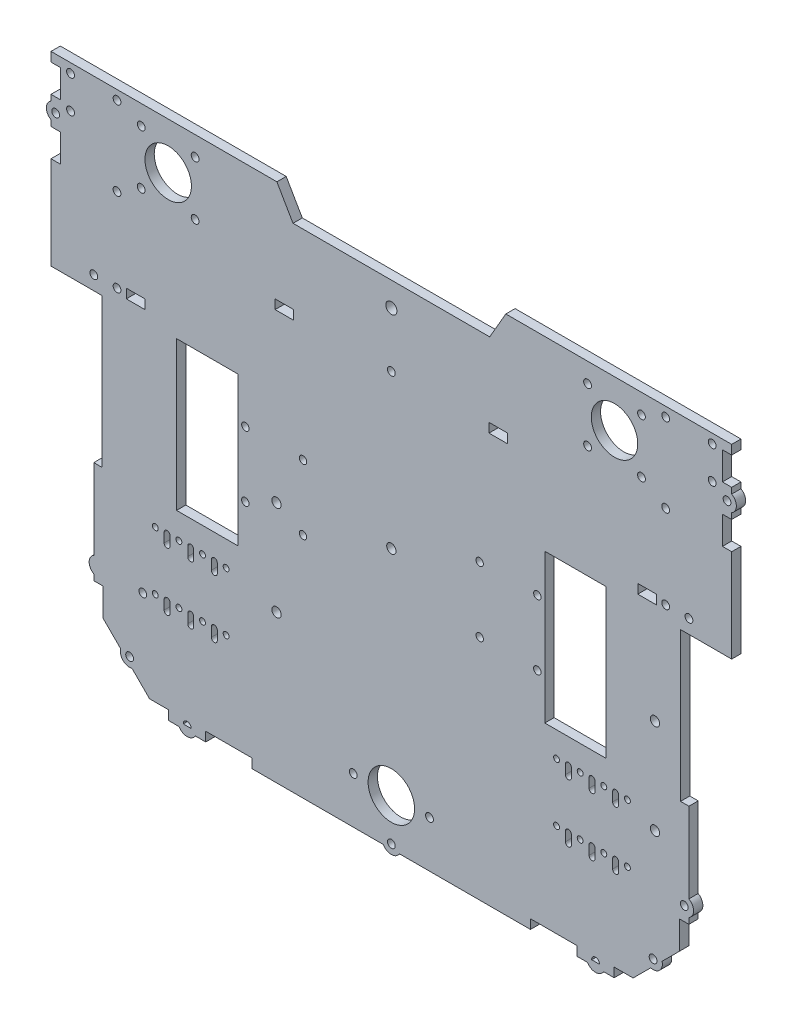
from build123d import *

# Parameters (mm, degrees)
SKETCH1_W            = 320
SKETCH1_H            = 280
BOSS_EXTRUDE1_DEPTH  = 5
SKETCH2_W            = 77.5
SKETCH2_H            = 80
CUT_EXTRUDE1_DEPTH   = 5
SKETCH3_W            = 17.5
SKETCH3_H            = 80
BOSS_EXTRUDE2_DEPTH  = 5
CUT_EXTRUDE8_DEPTH   = 5
SKETCH10_W           = 5
SKETCH10_H           = 100
BOSS_EXTRUDE3_DEPTH  = 20
SKETCH5_R            = 2.1
CUT_EXTRUDE9_DEPTH   = 10
SKETCH12_W           = 5
SKETCH12_H           = 35.2
SKETCH12_W_2         = 60.2
SKETCH12_H_2         = 5
CUT_EXTRUDE11_DEPTH  = 10
SKETCH15_R           = 2
SKETCH15_R_2         = 2.5
CUT_EXTRUDE13_DEPTH  = 10
SKETCH16_R           = 2.5
CUT_EXTRUDE14_DEPTH  = 10
SKETCH17_R           = 12.5
SKETCH17_R_2         = 2.1
CUT_EXTRUDE15_DEPTH  = 5
CUT_EXTRUDE17_DEPTH  = 10
SKETCH19_R           = 12.5
SKETCH19_R_2         = 2.1
CUT_EXTRUDE18_DEPTH  = 10
SKETCH21_W           = 5
SKETCH21_H           = 100
CUT_EXTRUDE20_DEPTH  = 3
SKETCH22_W           = 5
SKETCH22_H           = 100
CUT_EXTRUDE21_DEPTH  = 3
SKETCH23_R           = 2.1
CUT_EXTRUDE22_DEPTH  = 10
BOSS_EXTRUDE4_DEPTH  = 5
SKETCH26_W           = 20
SKETCH26_H           = 5
BOSS_EXTRUDE5_DEPTH  = 5
SKETCH27_R           = 2.1
CUT_EXTRUDE24_DEPTH  = 5
BOSS_EXTRUDE7_DEPTH  = 5
SKETCH30_W           = 5
SKETCH30_H           = 80
BOSS_EXTRUDE8_DEPTH  = 5
SKETCH31_W           = 5
SKETCH31_H           = 80
BOSS_EXTRUDE9_DEPTH  = 5
SKETCH32_R           = 2.1
CUT_EXTRUDE25_DEPTH  = 5
BOSS_EXTRUDE10_DEPTH = 5
SKETCH34_R           = 3
CUT_EXTRUDE26_DEPTH  = 5
SKETCH35_R           = 2.1
SKETCH35_W           = 10
SKETCH35_H           = 5
CUT_EXTRUDE27_DEPTH  = 5
SKETCH37_W           = 5
SKETCH37_H           = 5
BOSS_EXTRUDE11_DEPTH = 0.2
SKETCH38_W           = 5
SKETCH38_H           = 5
BOSS_EXTRUDE12_DEPTH = 0.2
SKETCH39_R           = 2.1
CUT_EXTRUDE28_DEPTH  = 5
BOSS_EXTRUDE13_DEPTH = 5
SKETCH42_R           = 1.5875
CUT_EXTRUDE29_DEPTH  = 10
SKETCH43_W           = 5
SKETCH43_H           = 100
BOSS_EXTRUDE14_DEPTH = 6
SKETCH44_W           = 5
SKETCH44_H           = 100
BOSS_EXTRUDE15_DEPTH = 6
SKETCH54_W           = 10
SKETCH54_H           = 5
CUT_EXTRUDE34_DEPTH  = 5
SKETCH56_W           = 4.979498839
SKETCH56_H           = 15
CUT_EXTRUDE36_DEPTH  = 5
SKETCH57_R           = 2.1
CUT_EXTRUDE37_DEPTH  = 10
SKETCH58_R           = 2.1
CUT_EXTRUDE38_DEPTH  = 5
BOSS_EXTRUDE21_DEPTH = 5
SKETCH60_W           = 5
SKETCH60_H           = 80
BOSS_EXTRUDE22_DEPTH = 17.5
SKETCH61_W           = 5
SKETCH61_H           = 80
BOSS_EXTRUDE23_DEPTH = 17.5
BOSS_EXTRUDE24_DEPTH = 5


with BuildPart() as part:
    # Sketch1 → Boss-Extrude1 (new body)
    with BuildSketch(Plane.XY):
        with Locations((-160, 140)):
            Rectangle(SKETCH1_W, SKETCH1_H)
    extrude(amount=BOSS_EXTRUDE1_DEPTH)

    # Sketch2 → Cut-Extrude1 (cut)
    with BuildSketch(Plane.XY.offset(5)):
        with Locations((-281.25, 140)):
            Rectangle(SKETCH2_W, SKETCH2_H)
        with Locations((-38.75, 140)):
            Rectangle(SKETCH2_W, SKETCH2_H)
    extrude(amount=-CUT_EXTRUDE1_DEPTH, mode=Mode.SUBTRACT)

    # Sketch3 → Boss-Extrude2 (add)
    with BuildSketch(Plane.XY.offset(5)):
        with Locations((-301.75, 140)):
            Rectangle(SKETCH3_W, SKETCH3_H)
        with Locations((-18.25, 140)):
            Rectangle(SKETCH3_W, SKETCH3_H)
    extrude(amount=-BOSS_EXTRUDE2_DEPTH)

    # Sketch9 → Cut-Extrude8 (cut)
    with BuildSketch(Plane(origin=(0, 0, 0), x_dir=(-1, 0, 0), z_dir=(0, 0, -1))):
        Polygon((210, 260), (260, 346.602540378), (210, 433.205080757), (110, 433.205080757), (60, 346.602540378), (110, 260), align=None)
    extrude(amount=-CUT_EXTRUDE8_DEPTH, mode=Mode.SUBTRACT)

    # Sketch10 → Boss-Extrude3 (add)
    with BuildSketch(Plane.ZY.offset(320)):
        with Locations((2.5, 230)):
            Rectangle(SKETCH10_W, SKETCH10_H)
    boss_extrude3 = extrude(amount=BOSS_EXTRUDE3_DEPTH)

    # Mirror2: Boss-Extrude3 across plane
    add(boss_extrude3.mirror(Plane(origin=(-160, 0, 0), x_dir=(0, 0, 1), z_dir=(1, 0, 0))))

    # Sketch5 → Cut-Extrude9 (cut)
    with BuildSketch(Plane.XY.offset(5)):
        with Locations((12.5, 257.5)):
            Circle(SKETCH5_R)
        with Locations((-12.5, 232.5)):
            Circle(SKETCH5_R)
        with Locations((-12.5, 187.5)):
            Circle(SKETCH5_R)
        with Locations((12.5, 162.5)):
            Circle(SKETCH5_R)
        with Locations((-12.5, 275)):
            Circle(SKETCH5_R)
        with Locations((12.5, 275)):
            Circle(SKETCH5_R)
    cut_extrude9 = extrude(amount=-CUT_EXTRUDE9_DEPTH, mode=Mode.SUBTRACT)

    # Mirror3: Cut-Extrude9 across plane
    add(cut_extrude9.mirror(Plane(origin=(-160, 0, 0), x_dir=(0, 0, 1), z_dir=(1, 0, 0))), mode=Mode.SUBTRACT)

    # Sketch12 → Cut-Extrude11 (cut)
    with BuildSketch(Plane.XY.offset(5)):
        with Locations((-2.5, 27.6)):
            Rectangle(SKETCH12_W, SKETCH12_H)
        with Locations((-317.5, 27.6)):
            Rectangle(SKETCH12_W, SKETCH12_H)
        with Locations((-264.9, 2.5)):
            Rectangle(SKETCH12_W_2, SKETCH12_H_2)
        with Locations((-55.1, 2.5)):
            Rectangle(SKETCH12_W_2, SKETCH12_H_2)
    extrude(amount=-CUT_EXTRUDE11_DEPTH, mode=Mode.SUBTRACT)

    # Sketch15 → Cut-Extrude13 (cut)
    with BuildSketch(Plane(origin=(0, 0, 0), x_dir=(-1, 0, 0), z_dir=(0, 0, -1))):
        with Locations((238.5, 122.5)):
            Circle(SKETCH15_R)
        with Locations((238.5, 157.5)):
            Circle(SKETCH15_R)
        with Locations((207.5, 157.5)):
            Circle(SKETCH15_R)
        with Locations((207.5, 122.5)):
            Circle(SKETCH15_R)
        with Locations((112.5, 122.5)):
            Circle(SKETCH15_R)
        with Locations((112.5, 157.5)):
            Circle(SKETCH15_R)
        with Locations((81.5, 157.5)):
            Circle(SKETCH15_R)
        with Locations((81.5, 122.5)):
            Circle(SKETCH15_R)
        with Locations((160, 140)):
            Circle(SKETCH15_R_2)
    extrude(amount=-CUT_EXTRUDE13_DEPTH, mode=Mode.SUBTRACT)

    # Sketch16 → Cut-Extrude14 (cut)
    with BuildSketch(Plane(origin=(0, 0, 0), x_dir=(-1, 0, 0), z_dir=(0, 0, -1))):
        with Locations((18.25, 130.5)):
            Circle(SKETCH16_R)
        with Locations((18.25, 79.5)):
            Circle(SKETCH16_R)
        with Locations((221.75, 79.5)):
            Circle(SKETCH16_R)
        with Locations((221.75, 130.5)):
            Circle(SKETCH16_R)
    extrude(amount=-CUT_EXTRUDE14_DEPTH, mode=Mode.SUBTRACT)

    # Sketch17 → Cut-Extrude15 (cut)
    with BuildSketch(Plane(origin=(0, 0, 0), x_dir=(-1, 0, 0), z_dir=(0, 0, -1))):
        with Locations((40, 255)):
            Circle(SKETCH17_R)
        with Locations((54.495689014, 240.504310986)):
            Circle(SKETCH17_R_2)
        with Locations((25.504310986, 269.495689014)):
            Circle(SKETCH17_R_2)
        with Locations((54.495689014, 269.495689014)):
            Circle(SKETCH17_R_2)
        with Locations((25.504310986, 240.504310986)):
            Circle(SKETCH17_R_2)
        with Locations((265.504310986, 269.495689014)):
            Circle(SKETCH17_R_2)
        with Locations((294.495689014, 240.504310986)):
            Circle(SKETCH17_R_2)
        with Locations((294.495689014, 269.495689014)):
            Circle(SKETCH17_R_2)
        with Locations((265.504310986, 240.504310986)):
            Circle(SKETCH17_R_2)
        with Locations((280, 255)):
            Circle(SKETCH17_R)
    extrude(amount=-CUT_EXTRUDE15_DEPTH, mode=Mode.SUBTRACT)

    # Sketch18 → Cut-Extrude17 (cut)
    with BuildSketch(Plane.XY.offset(5)):
        Polygon((-290, 5), (-315, 30), (-315, 10), (-320, 10), (-320, 0), (-295, 0), (-295, 5), align=None)
        Polygon((-30, 5), (-25, 5), (-25, 0), (0, 0), (0, 10), (-5, 10), (-5, 30), align=None)
    extrude(amount=-CUT_EXTRUDE17_DEPTH, mode=Mode.SUBTRACT)

    # Sketch19 → Cut-Extrude18 (cut)
    with BuildSketch(Plane(origin=(0, 0, 0), x_dir=(-1, 0, 0), z_dir=(0, 0, -1))):
        with Locations((160, 25)):
            Circle(SKETCH19_R)
        with Locations((139.5, 25)):
            Circle(SKETCH19_R_2)
        with Locations((180.5, 25)):
            Circle(SKETCH19_R_2)
    extrude(amount=-CUT_EXTRUDE18_DEPTH, mode=Mode.SUBTRACT)

    # Sketch21 → Cut-Extrude20 (cut)
    with BuildSketch(Plane.ZY.offset(340)):
        with Locations((2.5, 230)):
            Rectangle(SKETCH21_W, SKETCH21_H)
    extrude(amount=-CUT_EXTRUDE20_DEPTH, mode=Mode.SUBTRACT)

    # Sketch22 → Cut-Extrude21 (cut)
    with BuildSketch(Plane(origin=(20, 0, 0), x_dir=(0, 0, -1), z_dir=(1, 0, 0))):
        with Locations((-2.5, 230)):
            Rectangle(SKETCH22_W, SKETCH22_H)
    extrude(amount=-CUT_EXTRUDE21_DEPTH, mode=Mode.SUBTRACT)

    # Sketch23 → Cut-Extrude22 (cut)
    with BuildSketch(Plane(origin=(0, 0, 0), x_dir=(-1, 0, 0), z_dir=(0, 0, -1))):
        with Locations((160, 2.5)):
            Circle(SKETCH23_R)
    extrude(amount=-CUT_EXTRUDE22_DEPTH, mode=Mode.SUBTRACT)

    # Sketch24 → Boss-Extrude4 (add)
    with BuildSketch(Plane(origin=(0, 0, 0), x_dir=(-1, 0, 0), z_dir=(0, 0, -1))):
        with BuildLine():
            Line((164.330127019, 0), (155.669872981, 0))
            ThreePointArc((155.669872981, 0), (160, -2.5), (164.330127019, 0))
        make_face()
    extrude(amount=-BOSS_EXTRUDE4_DEPTH)

    # Sketch26 → Boss-Extrude5 (add)
    with BuildSketch(Plane.XZ.offset(-5)):
        with Locations((-50.2, 2.5)):
            Rectangle(SKETCH26_W, SKETCH26_H)
        with Locations((-269.8, 2.5)):
            Rectangle(SKETCH26_W, SKETCH26_H)
    extrude(amount=BOSS_EXTRUDE5_DEPTH)

    # Sketch27 → Cut-Extrude24 (cut)
    with BuildSketch(Plane(origin=(0, 0, 0), x_dir=(-1, 0, 0), z_dir=(0, 0, -1))):
        with Locations((50.2, 2.5)):
            Circle(SKETCH27_R)
        with Locations((269.8, 2.5)):
            Circle(SKETCH27_R)
    extrude(amount=-CUT_EXTRUDE24_DEPTH, mode=Mode.SUBTRACT)

    # Sketch29 → Boss-Extrude7 (add)
    with BuildSketch(Plane(origin=(0, 0, 0), x_dir=(-1, 0, 0), z_dir=(0, 0, -1))):
        with BuildLine():
            Line((274.797804323, 2.351838112), (264.802195677, 2.351838112))
            ThreePointArc((264.802195677, 2.351838112), (269.8, -2.5), (274.797804323, 2.351838112))
        make_face()
        with BuildLine():
            Line((45.202195677, 2.351838112), (55.197804323, 2.351838112))
            ThreePointArc((55.197804323, 2.351838112), (50.2, -2.5), (45.202195677, 2.351838112))
        make_face()
    extrude(amount=-BOSS_EXTRUDE7_DEPTH)

    # Sketch30 → Boss-Extrude8 (add)
    with BuildSketch(Plane(origin=(-9.5, 0, 0), x_dir=(0, 0, -1), z_dir=(1, 0, 0))):
        with Locations((-2.5, 140)):
            Rectangle(SKETCH30_W, SKETCH30_H)
    extrude(amount=BOSS_EXTRUDE8_DEPTH)

    # Sketch31 → Boss-Extrude9 (add)
    with BuildSketch(Plane.ZY.offset(310.5)):
        with Locations((2.5, 140)):
            Rectangle(SKETCH31_W, SKETCH31_H)
    extrude(amount=BOSS_EXTRUDE9_DEPTH)

    # Sketch32 → Cut-Extrude25 (cut)
    with BuildSketch(Plane(origin=(0, 0, 0), x_dir=(-1, 0, 0), z_dir=(0, 0, -1))):
        with Locations((19.267766953, 19.267766953)):
            Circle(SKETCH32_R)
    cut_extrude25 = extrude(amount=-CUT_EXTRUDE25_DEPTH, mode=Mode.SUBTRACT)

    # Sketch33 → Boss-Extrude10 (add)
    with BuildSketch(Plane(origin=(0, 0, 0), x_dir=(-1, 0, 0), z_dir=(0, 0, -1))):
        with BuildLine():
            Line((20.561862178, 14.438137822), (14.438137822, 20.561862178))
            ThreePointArc((14.438137822, 20.561862178), (15.732233047, 15.732233047), (20.561862178, 14.438137822))
        make_face()
    boss_extrude10 = extrude(amount=-BOSS_EXTRUDE10_DEPTH)

    # Mirror4: Cut-Extrude25, Boss-Extrude10 across plane
    add(cut_extrude25.mirror(Plane.ZY.offset(160)), mode=Mode.SUBTRACT)
    add(boss_extrude10.mirror(Plane.ZY.offset(160)))

    # Sketch34 → Cut-Extrude26 (cut)
    with BuildSketch(Plane.XY.offset(5)):
        with Locations((-160, 252)):
            Circle(SKETCH34_R)
    extrude(amount=-CUT_EXTRUDE26_DEPTH, mode=Mode.SUBTRACT)

    # Sketch35 → Cut-Extrude27 (cut)
    with BuildSketch(Plane(origin=(0, 0, 0), x_dir=(-1, 0, 0), z_dir=(0, 0, -1))):
        with Locations((160, 222.5)):
            Circle(SKETCH35_R)
        with Locations((102.5, 222.5)):
            Rectangle(SKETCH35_W, SKETCH35_H)
        with Locations((217.5, 222.5)):
            Rectangle(SKETCH35_W, SKETCH35_H)
    extrude(amount=-CUT_EXTRUDE27_DEPTH, mode=Mode.SUBTRACT)

    # Sketch37 → Boss-Extrude11 (add)
    with BuildSketch(Plane.XZ.offset(-45.2)):
        with Locations((-2.5, 2.5)):
            Rectangle(SKETCH37_W, SKETCH37_H)
    extrude(amount=BOSS_EXTRUDE11_DEPTH)

    # Sketch38 → Boss-Extrude12 (add)
    with BuildSketch(Plane.XZ.offset(-45.2)):
        with Locations((-317.5, 2.5)):
            Rectangle(SKETCH38_W, SKETCH38_H)
    extrude(amount=BOSS_EXTRUDE12_DEPTH)

    # Sketch39 → Cut-Extrude28 (cut)
    with BuildSketch(Plane(origin=(0, 0, 0), x_dir=(-1, 0, 0), z_dir=(0, 0, -1))):
        with Locations((2.5, 52.5)):
            Circle(SKETCH39_R)
        with Locations((293.638000549, 52.5)):
            Circle(SKETCH39_R)
    extrude(amount=-CUT_EXTRUDE28_DEPTH, mode=Mode.SUBTRACT)

    # Sketch40 → Boss-Extrude13 (add)
    with BuildSketch(Plane(origin=(0, 0, 0), x_dir=(-1, 0, 0), z_dir=(0, 0, -1))):
        with BuildLine():
            Line((0, 56.830127019), (0, 48.169872981))
            ThreePointArc((0, 48.169872981), (-2.5, 52.5), (0, 56.830127019))
        make_face()
        with BuildLine():
            Line((320, 56.830127019), (320, 48.169872981))
            ThreePointArc((320, 48.169872981), (322.5, 52.5), (320, 56.830127019))
        make_face()
    extrude(amount=-BOSS_EXTRUDE13_DEPTH)

    # Sketch42 → Cut-Extrude29 (cut)
    with BuildSketch(Plane.XY.offset(5)):
        with BuildLine():
            ThreePointArc((-63.225, 86.5), (-64.8125, 88.0875), (-66.4, 86.5))
            Line((-66.4, 86.5), (-66.4, 81.5))
            ThreePointArc((-66.4, 81.5), (-64.8125, 79.9125), (-63.225, 81.5))
            Line((-63.225, 81.5), (-63.225, 86.5))
        make_face()
        with BuildLine():
            ThreePointArc((-50.525, 86.5), (-52.1125, 88.0875), (-53.7, 86.5))
            Line((-53.7, 86.5), (-53.7, 81.5))
            ThreePointArc((-53.7, 81.5), (-52.1125, 79.9125), (-50.525, 81.5))
            Line((-50.525, 81.5), (-50.525, 86.5))
        make_face()
        with BuildLine():
            ThreePointArc((-37.825, 86.5), (-39.4125, 88.0875), (-41, 86.5))
            Line((-41, 86.5), (-41, 81.5))
            ThreePointArc((-41, 81.5), (-39.4125, 79.9125), (-37.825, 81.5))
            Line((-37.825, 81.5), (-37.825, 86.5))
        make_face()
        with BuildLine():
            ThreePointArc((-63.225, 55.25), (-64.8125, 56.8375), (-66.4, 55.25))
            Line((-66.4, 55.25), (-66.4, 50.25))
            ThreePointArc((-66.4, 50.25), (-64.8125, 48.6625), (-63.225, 50.25))
            Line((-63.225, 50.25), (-63.225, 55.25))
        make_face()
        with BuildLine():
            ThreePointArc((-50.525, 55.25), (-52.1125, 56.8375), (-53.7, 55.25))
            Line((-53.7, 55.25), (-53.7, 50.25))
            ThreePointArc((-53.7, 50.25), (-52.1125, 48.6625), (-50.525, 50.25))
            Line((-50.525, 50.25), (-50.525, 55.25))
        make_face()
        with BuildLine():
            ThreePointArc((-37.825, 55.25), (-39.4125, 56.8375), (-41, 55.25))
            Line((-41, 55.25), (-41, 50.25))
            ThreePointArc((-41, 50.25), (-39.4125, 48.6625), (-37.825, 50.25))
            Line((-37.825, 50.25), (-37.825, 55.25))
        make_face()
        with Locations((-71.1625, 55.25)):
            Circle(SKETCH42_R)
        with Locations((-58.4625, 55.25)):
            Circle(SKETCH42_R)
        with Locations((-45.7625, 55.25)):
            Circle(SKETCH42_R)
        with Locations((-33.0625, 55.25)):
            Circle(SKETCH42_R)
        with Locations((-33.0625, 86.5)):
            Circle(SKETCH42_R)
        with Locations((-45.7625, 86.5)):
            Circle(SKETCH42_R)
        with Locations((-71.1625, 86.5)):
            Circle(SKETCH42_R)
        with Locations((-58.4625, 86.5)):
            Circle(SKETCH42_R)
    cut_extrude29 = extrude(amount=-CUT_EXTRUDE29_DEPTH, mode=Mode.SUBTRACT)

    # Sketch43 → Boss-Extrude14 (add)
    with BuildSketch(Plane.ZY.offset(337)):
        with Locations((2.5, 230)):
            Rectangle(SKETCH43_W, SKETCH43_H)
    extrude(amount=BOSS_EXTRUDE14_DEPTH)

    # Sketch44 → Boss-Extrude15 (add)
    with BuildSketch(Plane(origin=(17, 0, 0), x_dir=(0, 0, -1), z_dir=(1, 0, 0))):
        with Locations((-2.5, 230)):
            Rectangle(SKETCH44_W, SKETCH44_H)
    extrude(amount=BOSS_EXTRUDE15_DEPTH)

    # Sketch54 → Cut-Extrude34 (cut)
    with BuildSketch(Plane(origin=(0, 0, 0), x_dir=(-1, 0, 0), z_dir=(0, 0, -1))):
        with Locations((22.5, 187.5)):
            Rectangle(SKETCH54_W, SKETCH54_H)
        with Locations((297.5, 187.5)):
            Rectangle(SKETCH54_W, SKETCH54_H)
    extrude(amount=-CUT_EXTRUDE34_DEPTH, mode=Mode.SUBTRACT)

    # Sketch56 → Cut-Extrude36 (cut)
    with BuildSketch(Plane(origin=(0, 0, 0), x_dir=(-1, 0, 0), z_dir=(0, 0, -1))):
        with Locations((-20.51025058, 237.5)):
            Rectangle(SKETCH56_W, SKETCH56_H)
        with Locations((-20.51025058, 267.5)):
            Rectangle(SKETCH56_W, SKETCH56_H)
    cut_extrude36 = extrude(amount=-CUT_EXTRUDE36_DEPTH, mode=Mode.SUBTRACT)

    # Mirror6: Cut-Extrude36 across plane
    add(cut_extrude36.mirror(Plane(origin=(-160, 0, 0), x_dir=(0, 0, 1), z_dir=(1, 0, 0))), mode=Mode.SUBTRACT)

    # Sketch57 → Cut-Extrude37 (cut)
    with BuildSketch(Plane(origin=(0, 0, 0), x_dir=(-1, 0, 0), z_dir=(0, 0, -1))):
        with Locations((320, 187.5)):
            Circle(SKETCH57_R)
        with Locations((0, 187.5)):
            Circle(SKETCH57_R)
    extrude(amount=-CUT_EXTRUDE37_DEPTH, mode=Mode.SUBTRACT)

    # Sketch58 → Cut-Extrude38 (cut)
    with BuildSketch(Plane.XY.offset(5)):
        with Locations((20.5, 252.5)):
            Circle(SKETCH58_R)
        with Locations((-340.5, 252.5)):
            Circle(SKETCH58_R)
    extrude(amount=-CUT_EXTRUDE38_DEPTH, mode=Mode.SUBTRACT)

    # Sketch59 → Boss-Extrude21 (add)
    with BuildSketch(Plane(origin=(0, 0, 0), x_dir=(-1, 0, 0), z_dir=(0, 0, -1))):
        with BuildLine():
            Line((343, 256.830127019), (343, 248.169872981))
            ThreePointArc((343, 248.169872981), (345.5, 252.5), (343, 256.830127019))
        make_face()
        with BuildLine():
            Line((-23, 256.830127019), (-23, 248.169872981))
            ThreePointArc((-23, 248.169872981), (-25.5, 252.5), (-23, 256.830127019))
        make_face()
    extrude(amount=-BOSS_EXTRUDE21_DEPTH)

    # Mirror7: Cut-Extrude29 across plane
    add(cut_extrude29.mirror(Plane(origin=(-160, 0, 0), x_dir=(0, 0, 1), z_dir=(1, 0, 0))), mode=Mode.SUBTRACT)

    # Sketch60 → Boss-Extrude22 (add)
    with BuildSketch(Plane.ZY.offset(27)):
        with Locations((2.5, 140)):
            Rectangle(SKETCH60_W, SKETCH60_H)
    extrude(amount=BOSS_EXTRUDE22_DEPTH)

    # Sketch61 → Boss-Extrude23 (add)
    with BuildSketch(Plane(origin=(-293, 0, 0), x_dir=(0, 0, -1), z_dir=(1, 0, 0))):
        with Locations((-2.5, 140)):
            Rectangle(SKETCH61_W, SKETCH61_H)
    extrude(amount=BOSS_EXTRUDE23_DEPTH)

    # Sketch62 → Boss-Extrude24 (add)
    with BuildSketch(Plane.XY.offset(5)):
        Polygon((-110, 260), (-210, 260), (-212.886751346, 265), (-107.113248654, 265), align=None)
    extrude(amount=-BOSS_EXTRUDE24_DEPTH)


solid = part.part
